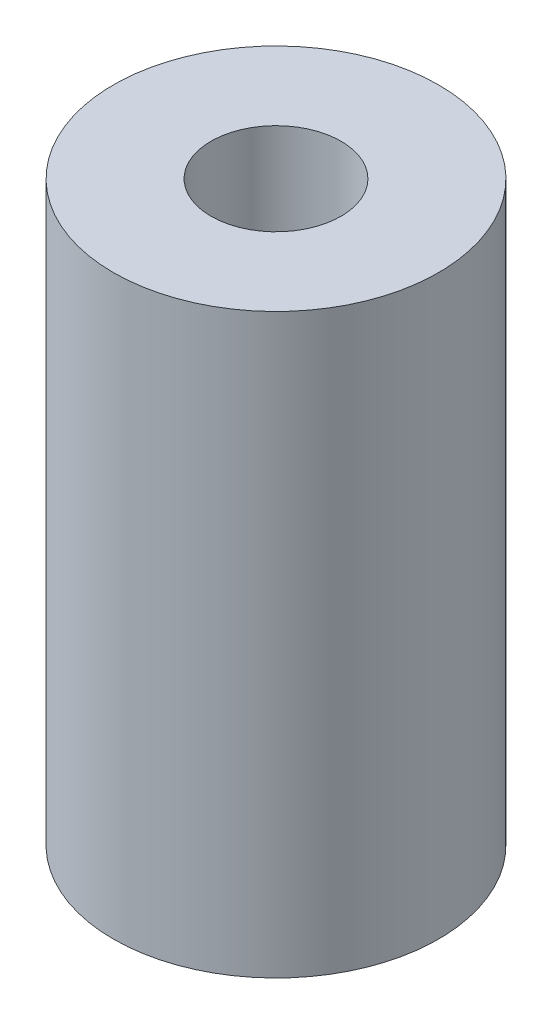
from build123d import *

# Parameters (mm, degrees)
SKETCH_1_R      = 4
SKETCH_1_R_2    = 1.6
EXTRUDE_1_DEPTH = 14.2


with BuildPart() as part:
    # 草图1 → 凸台-拉伸1 (new body)
    with BuildSketch(Plane(origin=(0, 0, 0), x_dir=(1, 0, 0), z_dir=(0, 1, 0))):
        Circle(SKETCH_1_R)
        Circle(SKETCH_1_R_2, mode=Mode.SUBTRACT)
    extrude(amount=EXTRUDE_1_DEPTH)


solid = part.part
